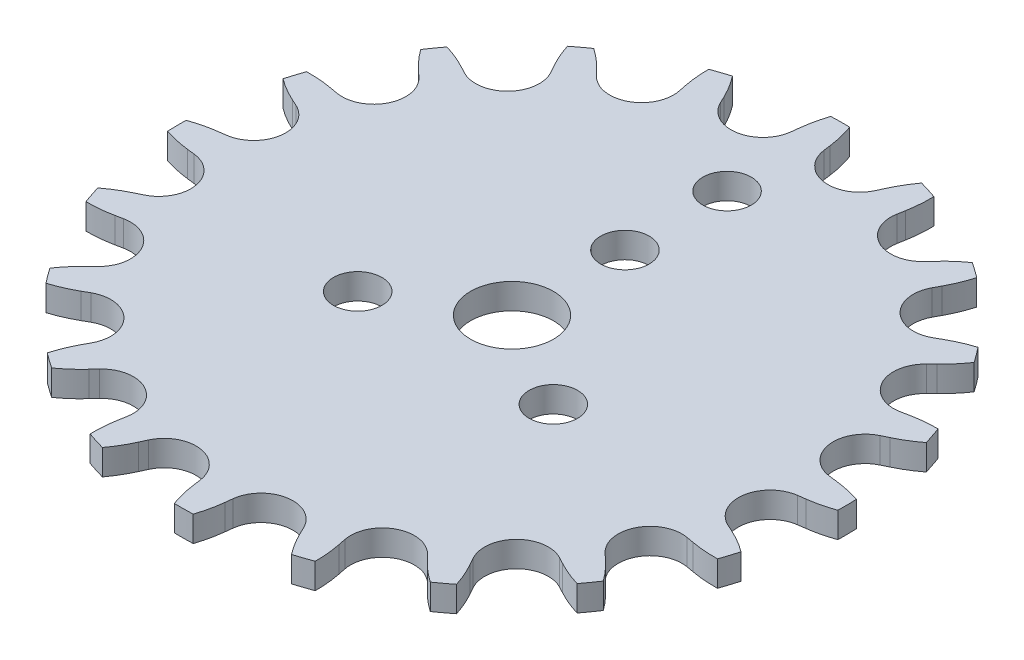
from build123d import *

# Parameters (mm, degrees)
SKETCH1_R           = 26
BOSS_EXTRUDE1_DEPTH = 2
SKETCH2_R           = 3.25
SKETCH2_R_2         = 1.9
CUT_EXTRUDE1_DEPTH  = 3
CUT_EXTRUDE2_DEPTH  = 10
CIRPATTERN1_COUNT   = 20


with BuildPart() as part:
    # Sketch1 → Boss-Extrude1 (new body)
    with BuildSketch(Plane(origin=(0, 0, 0), x_dir=(1, 0, 0), z_dir=(0, 1, 0))):
        Circle(SKETCH1_R)
    extrude(amount=BOSS_EXTRUDE1_DEPTH)

    # Sketch2 → Cut-Extrude1 (cut, through all)
    with BuildSketch(Plane(origin=(0, 2, 0), x_dir=(1, 0, 0), z_dir=(0, 1, 0))):
        Circle(SKETCH2_R)
        with Locations((0, 8.85)):
            Circle(SKETCH2_R_2)
        with Locations((7.664324823, -4.425)):
            Circle(SKETCH2_R_2)
        with Locations((-7.664324823, -4.425)):
            Circle(SKETCH2_R_2)
        with Locations((0, 16.85)):
            Circle(SKETCH2_R_2)
    extrude(amount=-CUT_EXTRUDE1_DEPTH, mode=Mode.SUBTRACT)

    # Sketch5 → Cut-Extrude2 (cut)
    with BuildSketch(Plane(origin=(0, 2, 0), x_dir=(1, 0, 0), z_dir=(0, 1, 0))):
        with BuildLine():
            ThreePointArc((-7.591229417, 24.867111532), (-7.001593879, 24.012811344), (-6.503694096, 23.101990458))
            Line((-6.503694096, 23.101990458), (-6.252916986, 22.580637882))
            ThreePointArc((-6.252916986, 22.580637882), (-3.583333333, 21.199285889), (-1.516070361, 23.381311098))
            Line((-1.516070361, 23.381311098), (-1.450578836, 23.95612283))
            ThreePointArc((-1.450578836, 23.95612283), (-1.279700655, 24.979987824), (-1.003606428, 25.980623051))
            ThreePointArc((-1.003606428, 25.980623051), (-4.333333333, 25.636345727), (-7.591229417, 24.867111532))
        make_face()
    cut_extrude2 = extrude(amount=-CUT_EXTRUDE2_DEPTH, mode=Mode.SUBTRACT)

    # CirPattern1: Cut-Extrude2 ×20 about axis
    cirpattern1_axis = Axis((0, 0, 0), (0, 1, 0))
    for i in range(1, CIRPATTERN1_COUNT):
        add(cut_extrude2.rotate(cirpattern1_axis, i * 360 / CIRPATTERN1_COUNT), mode=Mode.SUBTRACT)


solid = part.part
